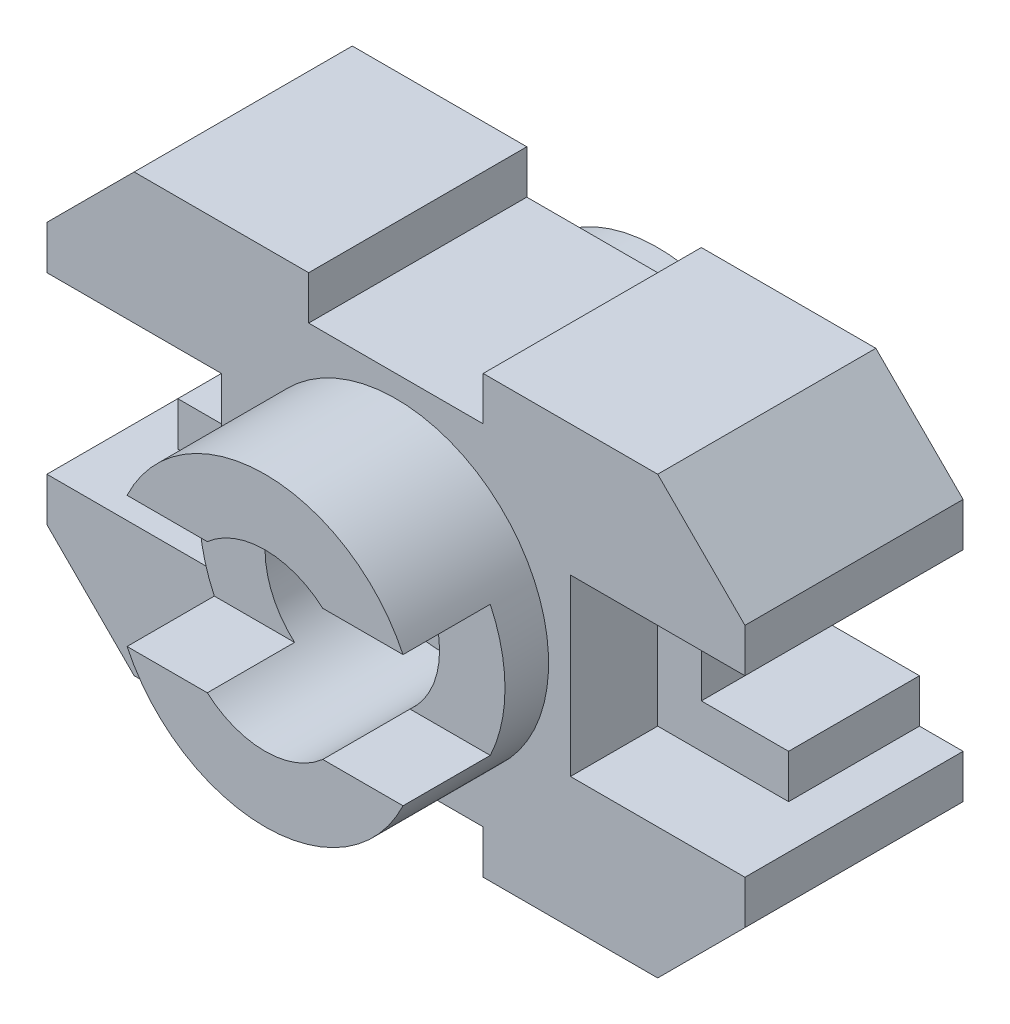
from build123d import *

# Parameters (mm, degrees)
SKETCH1_W           = 160
SKETCH1_H           = 100
BOSS_EXTRUDE2_DEPTH = 50
CUT_EXTRUDE2_DEPTH  = 50
CUT_EXTRUDE3_DEPTH  = 50
CUT_EXTRUDE4_DEPTH  = 20
CUT_EXTRUDE5_DEPTH  = 20
SKETCH8_W           = 40
SKETCH8_H           = 10
CUT_EXTRUDE6_DEPTH  = 125
SKETCH9_R           = 35
BOSS_EXTRUDE3_DEPTH = 10
SKETCH10_R          = 15
CUT_EXTRUDE8_DEPTH  = 123
SKETCH11_R          = 35
BOSS_EXTRUDE4_DEPTH = 30
SKETCH12_R          = 15
CUT_EXTRUDE9_DEPTH  = 30
SKETCH13_R          = 20
CUT_EXTRUDE10_DEPTH = 30
CUT_EXTRUDE11_DEPTH = 20
SKETCH15_R          = 20
SKETCH15_R_2        = 15
CUT_EXTRUDE12_DEPTH = 10


with BuildPart() as part:
    # Sketch1 → Boss-Extrude2 (new body)
    with BuildSketch(Plane.XY):
        with Locations((80, 50)):
            Rectangle(SKETCH1_W, SKETCH1_H)
    extrude(amount=BOSS_EXTRUDE2_DEPTH)

    # Sketch4 → Cut-Extrude2 (cut)
    with BuildSketch(Plane.XY.offset(50)):
        Polygon((0, 80), (20, 100), (0, 100), align=None)
        Polygon((0, 20), (20, 0), (0, 0), align=None)
        Polygon((140, 100), (160, 80), (160, 100), align=None)
        Polygon((160, 20), (140, 0), (160, 0), align=None)
    extrude(amount=-CUT_EXTRUDE2_DEPTH, mode=Mode.SUBTRACT)

    # Sketch5 → Cut-Extrude3 (cut)
    with BuildSketch(Plane.XY.offset(50)):
        Polygon((10, 70), (0, 70), (0, 30), (10, 30), (10, 40), (30, 40), (30, 60), (10, 60), align=None)
        Polygon((160, 30), (160, 70), (150, 70), (150, 60), (130, 60), (130, 40), (150, 40), (150, 30), align=None)
    extrude(amount=-CUT_EXTRUDE3_DEPTH, mode=Mode.SUBTRACT)

    # Sketch6 → Cut-Extrude4 (cut)
    with BuildSketch(Plane.XY.offset(50)):
        Polygon((10, 70), (40, 70), (40, 30), (10, 30), (10, 40), (30, 40), (30, 60), (10, 60), align=None)
    extrude(amount=-CUT_EXTRUDE4_DEPTH, mode=Mode.SUBTRACT)

    # Sketch7 → Cut-Extrude5 (cut)
    with BuildSketch(Plane.XY.offset(50)):
        Polygon((150, 70), (120, 70), (120, 30), (150, 30), (150, 40), (130, 40), (130, 60), (150, 60), align=None)
    extrude(amount=-CUT_EXTRUDE5_DEPTH, mode=Mode.SUBTRACT)

    # Sketch8 → Cut-Extrude6 (cut)
    with BuildSketch(Plane.XY.offset(50)):
        with Locations((80, 95)):
            Rectangle(SKETCH8_W, SKETCH8_H)
        with Locations((80, 5)):
            Rectangle(SKETCH8_W, SKETCH8_H)
    extrude(amount=-CUT_EXTRUDE6_DEPTH, mode=Mode.SUBTRACT)

    # Sketch9 → Boss-Extrude3 (add)
    with BuildSketch(Plane(origin=(0, 0, 0), x_dir=(-1, 0, 0), z_dir=(0, 0, -1))):
        with Locations((-80, 50)):
            Circle(SKETCH9_R)
    extrude(amount=BOSS_EXTRUDE3_DEPTH)

    # Sketch10 → Cut-Extrude8 (cut)
    with BuildSketch(Plane(origin=(0, 0, -10), x_dir=(-1, 0, 0), z_dir=(0, 0, -1))):
        with Locations((-80, 50)):
            Circle(SKETCH10_R)
    extrude(amount=-CUT_EXTRUDE8_DEPTH, mode=Mode.SUBTRACT)

    # Sketch11 → Boss-Extrude4 (add)
    with BuildSketch(Plane.XY.offset(50)):
        with Locations((80, 50)):
            Circle(SKETCH11_R)
    extrude(amount=BOSS_EXTRUDE4_DEPTH)

    # Sketch12 → Cut-Extrude9 (cut)
    with BuildSketch(Plane(origin=(0, 0, 50), x_dir=(-1, 0, 0), z_dir=(0, 0, -1))):
        with Locations((-80, 50)):
            Circle(SKETCH12_R)
    extrude(amount=-CUT_EXTRUDE9_DEPTH, mode=Mode.SUBTRACT)

    # Sketch13 → Cut-Extrude10 (cut)
    with BuildSketch(Plane.XY.offset(80)):
        with Locations((80, 50)):
            Circle(SKETCH13_R)
    extrude(amount=-CUT_EXTRUDE10_DEPTH, mode=Mode.SUBTRACT)

    # Sketch14 → Cut-Extrude11 (cut)
    with BuildSketch(Plane.XY.offset(80)):
        with BuildLine():
            ThreePointArc((66.771243445, 35), (60, 50), (66.771243445, 65))
            Line((66.771243445, 65), (48.377223398, 65))
            ThreePointArc((48.377223398, 65), (45, 50), (48.377223398, 35))
            Line((48.377223398, 35), (66.771243445, 35))
        make_face()
        with BuildLine():
            Line((111.622776602, 65), (93.228756555, 65))
            ThreePointArc((93.228756555, 65), (98.228756555, 58.228756555), (100, 50))
            ThreePointArc((100, 50), (98.228756555, 41.771243445), (93.228756555, 35))
            Line((93.228756555, 35), (111.622776602, 35))
            ThreePointArc((111.622776602, 35), (114.145257219, 42.312255892), (115, 50))
            ThreePointArc((115, 50), (114.145257219, 57.687744108), (111.622776602, 65))
        make_face()
    extrude(amount=-CUT_EXTRUDE11_DEPTH, mode=Mode.SUBTRACT)

    # Sketch15 → Cut-Extrude12 (cut)
    with BuildSketch(Plane.XY.offset(50)):
        with Locations((80, 50)):
            Circle(SKETCH15_R)
        with Locations((80, 50)):
            Circle(SKETCH15_R_2, mode=Mode.SUBTRACT)
    extrude(amount=-CUT_EXTRUDE12_DEPTH, mode=Mode.SUBTRACT)


solid = part.part
